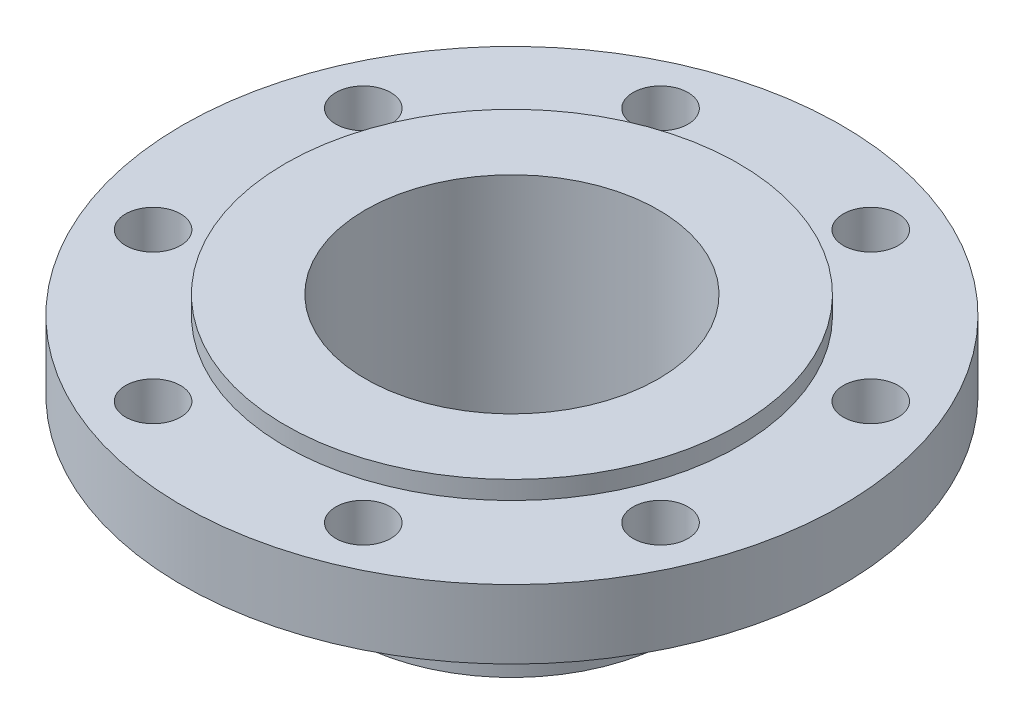
from build123d import *

# Parameters (mm, degrees)
BORESKETCH_R       = 50.8
BORE_DEPTH         = 75.676
SKETCH3_R          = 9.525
BOLT_HOLE_DEPTH    = 69.326
BOLT_PATTERN_COUNT = 8


with BuildPart() as part:
    # Main → Revolve1 (revolve)
    with BuildSketch(Plane.XY):
        Polygon((0, 0), (-78.613, 0), (-78.613, -6.35), (-114.3, -6.35), (-114.3, -30.226), (-67.437, -30.226), (-57.15, -66.378666667), (-57.15, -74.676), (0, -74.676), align=None)
    revolve(axis=Axis((0, 0, 0), (0, -1, 0)))

    # BoreSketch → Bore (cut, through all)
    with BuildSketch(Plane(origin=(0, 0, 0), x_dir=(1, 0, 0), z_dir=(0, 1, 0))):
        Circle(BORESKETCH_R)
    extrude(amount=-BORE_DEPTH, mode=Mode.SUBTRACT)

    # Sketch3 → Bolt Hole (cut, through all)
    with BuildSketch(Plane(origin=(0, -6.35, 0), x_dir=(1, 0, 0), z_dir=(0, 1, 0))):
        with Locations((-36.450596933, 87.999525472)):
            Circle(SKETCH3_R)
    bolt_hole = extrude(amount=-BOLT_HOLE_DEPTH, mode=Mode.SUBTRACT)

    # Bolt Pattern: Bolt Hole ×8 about axis
    bolt_pattern_axis = Axis((0, 0, 0), (0, 1, 0))
    for i in range(1, BOLT_PATTERN_COUNT):
        add(bolt_hole.rotate(bolt_pattern_axis, i * 360 / BOLT_PATTERN_COUNT), mode=Mode.SUBTRACT)


solid = part.part
